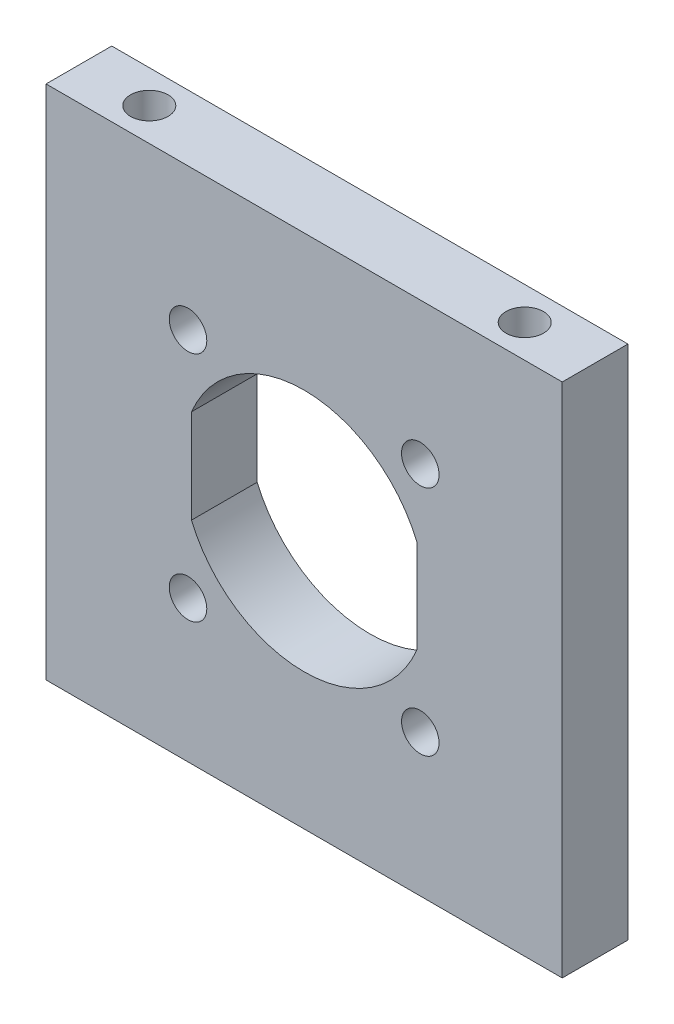
from build123d import *

# Parameters (mm, degrees)
SKETCH1_W           = 55
SKETCH1_H           = 55
SKETCH1_R           = 2
BOSS_EXTRUDE1_DEPTH = 7
SKETCH2_R           = 2
CUT_EXTRUDE1_DEPTH  = 9
SKETCH3_R           = 2
CUT_EXTRUDE2_DEPTH  = 9


with BuildPart() as part:
    # Sketch1 → Boss-Extrude1 (new body)
    with BuildSketch(Plane.XY):
        Rectangle(SKETCH1_W, SKETCH1_H)
        with Locations((-12.374368671, 12.374368671)):
            Circle(SKETCH1_R, mode=Mode.SUBTRACT)
        with Locations((12.374368671, 12.374368671)):
            Circle(SKETCH1_R, mode=Mode.SUBTRACT)
        with Locations((12.374368671, -12.374368671)):
            Circle(SKETCH1_R, mode=Mode.SUBTRACT)
        with Locations((-12.374368671, -12.374368671)):
            Circle(SKETCH1_R, mode=Mode.SUBTRACT)
        with BuildLine():
            Line((12, 5), (12, -5))
            ThreePointArc((12, -5), (0, -13), (-12, -5))
            Line((-12, -5), (-12, 5))
            ThreePointArc((-12, 5), (0, 13), (12, 5))
        make_face(mode=Mode.SUBTRACT)
    extrude(amount=BOSS_EXTRUDE1_DEPTH)

    # Sketch2 → Cut-Extrude1 (cut)
    with BuildSketch(Plane(origin=(0, 27.5, 0), x_dir=(1, 0, 0), z_dir=(0, 1, 0))):
        with Locations((-20, -3.5)):
            Circle(SKETCH2_R)
        with Locations((20, -3.5)):
            Circle(SKETCH2_R)
    extrude(amount=-CUT_EXTRUDE1_DEPTH, mode=Mode.SUBTRACT)

    # Sketch3 → Cut-Extrude2 (cut)
    with BuildSketch(Plane.XZ.offset(27.5)):
        with Locations((-20, 3.5)):
            Circle(SKETCH3_R)
        with Locations((20, 3.5)):
            Circle(SKETCH3_R)
    extrude(amount=-CUT_EXTRUDE2_DEPTH, mode=Mode.SUBTRACT)


solid = part.part
